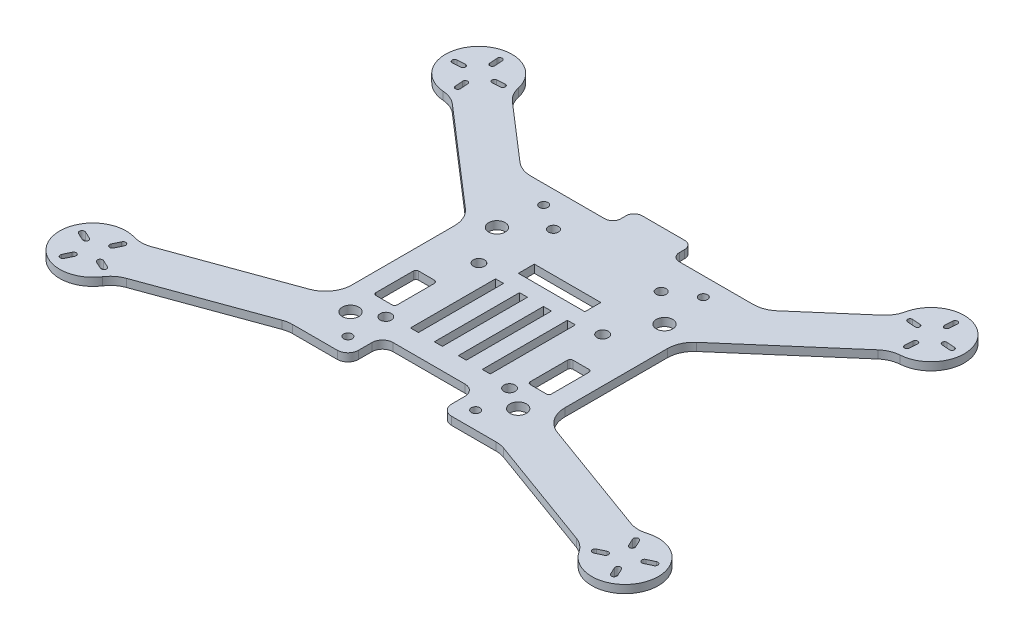
from build123d import *

# Parameters (mm, degrees)
BOSS_EXTRUDE1_DEPTH      = 3
FILLET1_R                = 10
FILLET2_R                = 10
SKETCH3_R                = 2.11
CUT_EXTRUDE2_DEPTH       = 4
SKETCH7_W                = 35
SKETCH7_H                = 13
CUT_EXTRUDE6_DEPTH       = 4
FILLET3_R                = 4
SKETCH8_R                = 3.1
CUT_EXTRUDE7_DEPTH       = 4
SKETCH9_R                = 1.875
CUT_EXTRUDE8_DEPTH       = 4
SKETCH10_W               = 22
SKETCH10_H               = 8
BOSS_EXTRUDE2_DEPTH      = 3
FILLET4_R                = 3
SKETCH11_W               = 8
SKETCH11_H               = 16
CUT_EXTRUDE9_DEPTH       = 4
FILLET5_R                = 1
SKETCH12_R               = 1.6
CUT_EXTRUDE10_DEPTH      = 4
SKETCH13_W               = 3
SKETCH13_H               = 32
CUT_EXTRUDE11_DEPTH      = 4
CUT_EXTRUDE12_DEPTH      = 1
CUT_EXTRUDE12_DEPTH_BACK = 4
SKETCH15_W               = 25
SKETCH15_H               = 6
CUT_EXTRUDE13_DEPTH      = 4


with BuildPart() as part:
    # Sketch1 → Boss-Extrude1 (new body)
    with BuildSketch(Plane(origin=(0, 0, 0), x_dir=(1, 0, 0), z_dir=(0, 1, 0))):
        with BuildLine():
            Line((-40, 24.054255384), (-82.97600741, 61.267926756))
            ThreePointArc((-82.97600741, 61.267926756), (-94.449617004, 81.785564091), (-72.502295388, 73.363436521))
            Line((-72.502295388, 73.363436521), (-45.521156897, 50))
            Line((-45.521156897, 50), (45.521156897, 50))
            Line((45.521156897, 50), (72.502295388, 73.363436521))
            ThreePointArc((72.502295388, 73.363436521), (94.449617004, 81.785564091), (82.97600741, 61.267926756))
            Line((82.97600741, 61.267926756), (40, 24.054255384))
            Line((40, 24.054255384), (40, -26.045387191))
            Line((40, -26.045387191), (93.710708253, -45.594486256))
            ThreePointArc((93.710708253, -45.594486256), (111.74615776, -60.672275218), (88.23838596, -60.629568189))
            Line((88.23838596, -60.629568189), (40, -43.07223155))
            Line((40, -43.07223155), (-40, -43.07223155))
            Line((-40, -43.07223155), (-88.23838596, -60.629568189))
            ThreePointArc((-88.23838596, -60.629568189), (-111.74615776, -60.672275218), (-93.710708253, -45.594486256))
            Line((-93.710708253, -45.594486256), (-40, -26.045387191))
            Line((-40, -26.045387191), (-40, 24.054255384))
        make_face()
    extrude(amount=BOSS_EXTRUDE1_DEPTH)

    # Fillet1
    fillet1_edges = [part.edges().sort_by_distance(p)[0] for p in [
        (45.521156897, 1.5, -50),
        (40, 1.5, -24.054255384),
        (40, 1.5, 26.045387191),
        (40, 1.5, 43.07223155),
        (-40, 1.5, 43.07223155),
        (-40, 1.5, 26.045387191),
        (-40, 1.5, -24.054255384),
        (-45.521156897, 1.5, -50),
    ]]
    fillet(fillet1_edges, radius=FILLET1_R)

    # Fillet2
    fillet2_edges = [part.edges().sort_by_distance(p)[0] for p in [
        (72.502295388, 1.5, -73.363436521),
        (82.97600741, 1.5, -61.267926756),
        (93.710708253, 1.5, 45.594486256),
        (88.23838596, 1.5, 60.629568189),
        (-88.23838596, 1.5, 60.629568189),
        (-93.710708253, 1.5, 45.594486256),
        (-82.97600741, 1.5, -61.267926756),
        (-72.502295388, 1.5, -73.363436521),
    ]]
    fillet(fillet2_edges, radius=FILLET2_R)

    # Sketch3 → Cut-Extrude2 (cut, through all)
    with BuildSketch(Plane(origin=(0, 3, 0), x_dir=(1, 0, 0), z_dir=(0, 1, 0))):
        with Locations((-23.25, -23.07223155)):
            Circle(SKETCH3_R)
        with Locations((23.25, -23.07223155)):
            Circle(SKETCH3_R)
        with Locations((23.25, 11.92776845)):
            Circle(SKETCH3_R)
        with Locations((-23.25, 11.92776845)):
            Circle(SKETCH3_R)
    extrude(amount=-CUT_EXTRUDE2_DEPTH, mode=Mode.SUBTRACT)

    # Sketch7 → Cut-Extrude6 (cut, through all)
    with BuildSketch(Plane.XZ):
        with Locations((0, 36.57223155)):
            Rectangle(SKETCH7_W, SKETCH7_H)
    extrude(amount=-CUT_EXTRUDE6_DEPTH, mode=Mode.SUBTRACT)

    # Fillet3
    fillet3_edges = [part.edges().sort_by_distance(p)[0] for p in [
        (-17.5, 1.5, 43.07223155),
        (17.5, 1.5, 43.07223155),
        (17.5, 1.5, 30.07223155),
        (-17.5, 1.5, 30.07223155),
    ]]
    fillet(fillet3_edges, radius=FILLET3_R)

    # Sketch8 → Cut-Extrude7 (cut, through all)
    with BuildSketch(Plane(origin=(0, 3, 0), x_dir=(1, 0, 0), z_dir=(0, 1, 0))):
        with Locations((-31.5, -28.07223155)):
            Circle(SKETCH8_R)
        with Locations((31.5, -28.07223155)):
            Circle(SKETCH8_R)
        with Locations((-31.5, 26.92776845)):
            Circle(SKETCH8_R)
        with Locations((31.5, 26.92776845)):
            Circle(SKETCH8_R)
    extrude(amount=-CUT_EXTRUDE7_DEPTH, mode=Mode.SUBTRACT)

    # Sketch9 → Cut-Extrude8 (cut, through all)
    with BuildSketch(Plane(origin=(0, 3, 0), x_dir=(1, 0, 0), z_dir=(0, 1, 0))):
        with Locations((-20.25, 36.92776845)):
            Circle(SKETCH9_R)
        with Locations((20.25, 36.92776845)):
            Circle(SKETCH9_R)
    extrude(amount=-CUT_EXTRUDE8_DEPTH, mode=Mode.SUBTRACT)

    # Sketch10 → Boss-Extrude2 (add)
    with BuildSketch(Plane(origin=(0, 3, 0), x_dir=(1, 0, 0), z_dir=(0, 1, 0))):
        with Locations((0, 54)):
            Rectangle(SKETCH10_W, SKETCH10_H)
    extrude(amount=-BOSS_EXTRUDE2_DEPTH)

    # Fillet4
    fillet4_edges = [part.edges().sort_by_distance(p)[0] for p in [
        (-11, 1.5, -50),
        (-11, 1.5, -58),
        (11, 1.5, -58),
        (11, 1.5, -50),
    ]]
    fillet(fillet4_edges, radius=FILLET4_R)

    # Sketch11 → Cut-Extrude9 (cut, through all)
    with BuildSketch(Plane(origin=(0, 3, 0), x_dir=(1, 0, 0), z_dir=(0, 1, 0))):
        with Locations((-29, -10)):
            Rectangle(SKETCH11_W, SKETCH11_H)
        with Locations((29, -10)):
            Rectangle(SKETCH11_W, SKETCH11_H)
    extrude(amount=-CUT_EXTRUDE9_DEPTH, mode=Mode.SUBTRACT)

    # Fillet5
    fillet5_edges = [part.edges().sort_by_distance(p)[0] for p in [
        (-33, 1.5, 18),
        (-33, 1.5, 2),
        (-25, 1.5, 2),
        (-25, 1.5, 18),
        (25, 1.5, 2),
        (33, 1.5, 2),
        (33, 1.5, 18),
        (25, 1.5, 18),
    ]]
    fillet(fillet5_edges, radius=FILLET5_R)

    # Sketch12 → Cut-Extrude10 (cut, through all)
    with BuildSketch(Plane(origin=(0, 3, 0), x_dir=(1, 0, 0), z_dir=(0, 1, 0))):
        with Locations((-30, 43)):
            Circle(SKETCH12_R)
        with Locations((30, 43)):
            Circle(SKETCH12_R)
        with Locations((-24, -36.57223155)):
            Circle(SKETCH12_R)
        with Locations((24, -36.57223155)):
            Circle(SKETCH12_R)
    extrude(amount=-CUT_EXTRUDE10_DEPTH, mode=Mode.SUBTRACT)

    # Sketch13 → Cut-Extrude11 (cut, through all)
    with BuildSketch(Plane(origin=(0, 3, 0), x_dir=(1, 0, 0), z_dir=(0, 1, 0))):
        with Locations((-13.5, -6.07223155)):
            Rectangle(SKETCH13_W, SKETCH13_H)
        with Locations((-4.5, -6.07223155)):
            Rectangle(SKETCH13_W, SKETCH13_H)
        with Locations((4.5, -6.07223155)):
            Rectangle(SKETCH13_W, SKETCH13_H)
        with Locations((13.5, -6.07223155)):
            Rectangle(SKETCH13_W, SKETCH13_H)
    extrude(amount=-CUT_EXTRUDE11_DEPTH, mode=Mode.SUBTRACT)

    # Sketch14 → Cut-Extrude12 (cut, two sides)
    with BuildSketch(Plane(origin=(0, 3, 0), x_dir=(1, 0, 0), z_dir=(0, 1, 0))) as cut_extrude12_sk:
        with BuildLine():
            Line((-84.711543797, 82.145622125), (-84.496521763, 79.153337793))
            ThreePointArc((-84.496521763, 79.153337793), (-85.329700452, 78.191145883), (-86.291892362, 79.024324572))
            Line((-86.291892362, 79.024324572), (-86.506914396, 82.016608904))
            ThreePointArc((-86.506914396, 82.016608904), (-85.673735707, 82.978800814), (-84.711543797, 82.145622125))
        make_face()
        with BuildLine():
            Line((-93.542645552, 73.891432776), (-90.550361219, 74.106454811))
            ThreePointArc((-90.550361219, 74.106454811), (-89.588169309, 73.273276121), (-90.421347999, 72.311084211))
            Line((-90.421347999, 72.311084211), (-93.413632331, 72.096062177))
            ThreePointArc((-93.413632331, 72.096062177), (-94.375824241, 72.929240867), (-93.542645552, 73.891432776))
        make_face()
        with BuildLine():
            Line((-83.493085604, 65.189344242), (-83.708107638, 68.181628575))
            ThreePointArc((-83.708107638, 68.181628575), (-84.670299548, 69.014807264), (-85.503478237, 68.052615354))
            Line((-85.503478237, 68.052615354), (-85.288456203, 65.060331022))
            ThreePointArc((-85.288456203, 65.060331022), (-84.326264293, 64.227152332), (-83.493085604, 65.189344242))
        make_face()
        with BuildLine():
            Line((-76.586367669, 75.10989097), (-79.578652001, 74.894868936))
            ThreePointArc((-79.578652001, 74.894868936), (-80.411830691, 73.932677026), (-79.449638781, 73.099498336))
            Line((-79.449638781, 73.099498336), (-76.457354448, 73.31452037))
            ThreePointArc((-76.457354448, 73.31452037), (-75.624175759, 74.27671228), (-76.586367669, 75.10989097))
        make_face()
        with BuildLine():
            Line((84.711543797, 82.145622125), (84.496521763, 79.153337793))
            ThreePointArc((84.496521763, 79.153337793), (85.329700452, 78.191145883), (86.291892362, 79.024324572))
            Line((86.291892362, 79.024324572), (86.506914396, 82.016608904))
            ThreePointArc((86.506914396, 82.016608904), (85.673735707, 82.978800814), (84.711543797, 82.145622125))
        make_face()
        with BuildLine():
            Line((93.542645552, 73.891432776), (90.550361219, 74.106454811))
            ThreePointArc((90.550361219, 74.106454811), (89.588169309, 73.273276121), (90.421347999, 72.311084211))
            Line((90.421347999, 72.311084211), (93.413632331, 72.096062177))
            ThreePointArc((93.413632331, 72.096062177), (94.375824241, 72.929240867), (93.542645552, 73.891432776))
        make_face()
        with BuildLine():
            Line((83.493085604, 65.189344242), (83.708107638, 68.181628575))
            ThreePointArc((83.708107638, 68.181628575), (84.670299548, 69.014807264), (85.503478237, 68.052615354))
            Line((85.503478237, 68.052615354), (85.288456203, 65.060331022))
            ThreePointArc((85.288456203, 65.060331022), (84.326264293, 64.227152332), (83.493085604, 65.189344242))
        make_face()
        with BuildLine():
            Line((76.586367669, 75.10989097), (79.578652001, 74.894868936))
            ThreePointArc((79.578652001, 74.894868936), (80.411830691, 73.932677026), (79.449638781, 73.099498336))
            Line((79.449638781, 73.099498336), (76.457354448, 73.31452037))
            ThreePointArc((76.457354448, 73.31452037), (75.624175759, 74.27671228), (76.586367669, 75.10989097))
        make_face()
        with BuildLine():
            Line((-95.501436988, -49.116025499), (-96.769291773, -51.83494886))
            ThreePointArc((-96.769291773, -51.83494886), (-98.098217822, -52.318638385), (-98.581907347, -50.989712336))
            Line((-98.581907347, -50.989712336), (-97.314052562, -48.270788975))
            ThreePointArc((-97.314052562, -48.270788975), (-95.985126513, -47.78709945), (-95.501436988, -49.116025499))
        make_face()
        with BuildLine():
            Line((-102.685947438, -64.523257878), (-101.418092653, -61.804334517))
            ThreePointArc((-101.418092653, -61.804334517), (-101.901782178, -60.475408468), (-103.230708227, -60.959097994))
            Line((-103.230708227, -60.959097994), (-104.498563012, -63.678021355))
            ThreePointArc((-104.498563012, -63.678021355), (-104.014873487, -65.006947403), (-102.685947438, -64.523257878))
        make_face()
        with BuildLine():
            Line((-107.280997928, -51.898460415), (-104.562074567, -53.1663152))
            ThreePointArc((-104.562074567, -53.1663152), (-104.078385042, -54.495241249), (-105.40731109, -54.978930774))
            Line((-105.40731109, -54.978930774), (-108.126234452, -53.711075989))
            ThreePointArc((-108.126234452, -53.711075989), (-108.609923977, -52.38214994), (-107.280997928, -51.898460415))
        make_face()
        with BuildLine():
            Line((-91.873765548, -59.082970864), (-94.59268891, -57.815116079))
            ThreePointArc((-94.59268891, -57.815116079), (-95.921614958, -58.298805604), (-95.437925433, -59.627731653))
            Line((-95.437925433, -59.627731653), (-92.719002072, -60.895586438))
            ThreePointArc((-92.719002072, -60.895586438), (-91.390076023, -60.411896913), (-91.873765548, -59.082970864))
        make_face()
        with BuildLine():
            Line((95.501436988, -49.116025499), (96.769291773, -51.83494886))
            ThreePointArc((96.769291773, -51.83494886), (98.098217822, -52.318638385), (98.581907347, -50.989712336))
            Line((98.581907347, -50.989712336), (97.314052562, -48.270788975))
            ThreePointArc((97.314052562, -48.270788975), (95.985126513, -47.78709945), (95.501436988, -49.116025499))
        make_face()
        with BuildLine():
            Line((102.685947438, -64.523257878), (101.418092653, -61.804334517))
            ThreePointArc((101.418092653, -61.804334517), (101.901782178, -60.475408468), (103.230708227, -60.959097994))
            Line((103.230708227, -60.959097994), (104.498563012, -63.678021355))
            ThreePointArc((104.498563012, -63.678021355), (104.014873487, -65.006947403), (102.685947438, -64.523257878))
        make_face()
        with BuildLine():
            Line((107.280997928, -51.898460415), (104.562074567, -53.1663152))
            ThreePointArc((104.562074567, -53.1663152), (104.078385042, -54.495241249), (105.40731109, -54.978930774))
            Line((105.40731109, -54.978930774), (108.126234452, -53.711075989))
            ThreePointArc((108.126234452, -53.711075989), (108.609923977, -52.38214994), (107.280997928, -51.898460415))
        make_face()
        with BuildLine():
            Line((91.873765548, -59.082970864), (94.59268891, -57.815116079))
            ThreePointArc((94.59268891, -57.815116079), (95.921614958, -58.298805604), (95.437925433, -59.627731653))
            Line((95.437925433, -59.627731653), (92.719002072, -60.895586438))
            ThreePointArc((92.719002072, -60.895586438), (91.390076023, -60.411896913), (91.873765548, -59.082970864))
        make_face()
    extrude(amount=CUT_EXTRUDE12_DEPTH, mode=Mode.SUBTRACT)
    extrude(cut_extrude12_sk.sketch, amount=-CUT_EXTRUDE12_DEPTH_BACK, mode=Mode.SUBTRACT)

    # Sketch15 → Cut-Extrude13 (cut, through all)
    with BuildSketch(Plane(origin=(0, 3, 0), x_dir=(1, 0, 0), z_dir=(0, 1, 0))):
        with Locations((0, 19)):
            Rectangle(SKETCH15_W, SKETCH15_H)
    extrude(amount=-CUT_EXTRUDE13_DEPTH, mode=Mode.SUBTRACT)


solid = part.part
